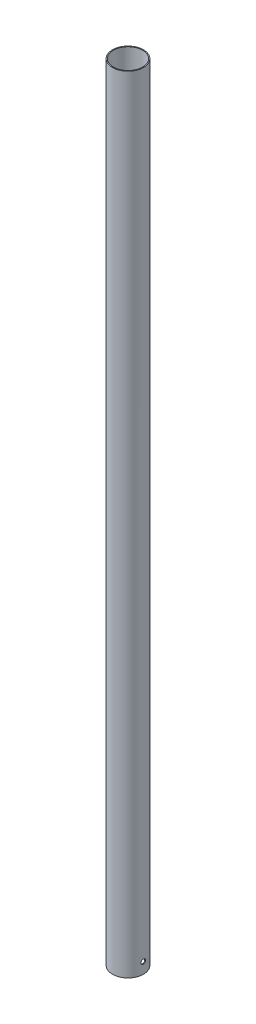
from build123d import *

# Parameters (mm, degrees)
SKETCH1_R           = 70.65
SKETCH1_R_2         = 66.69
BOSS_EXTRUDE1_DEPTH = 3588
CUT_EXTRUDE1_REACH  = 72.65
SKETCH3_R           = 10.5


with BuildPart() as part:
    # Sketch1 → Boss-Extrude1 (new body)
    with BuildSketch(Plane(origin=(0, 0, 0), x_dir=(1, 0, 0), z_dir=(0, 1, 0))):
        Circle(SKETCH1_R)
        Circle(SKETCH1_R_2, mode=Mode.SUBTRACT)
    extrude(amount=BOSS_EXTRUDE1_DEPTH)

    # Sketch3 → Cut-Extrude1 (cut, up to next)
    with BuildSketch(Plane(origin=(0, 0, 0), x_dir=(0, 0, -1), z_dir=(1, 0, 0)), mode=Mode.PRIVATE) as cut_extrude1_sk1:
        with Locations((0, 50)):
            Circle(SKETCH3_R)
    cut_extrude1_tool1 = extrude(cut_extrude1_sk1.sketch, amount=CUT_EXTRUDE1_REACH, mode=Mode.PRIVATE) & part.part
    add(cut_extrude1_tool1.solids().sort_by_distance((0, 50, 0))[0], mode=Mode.SUBTRACT)


solid = part.part
